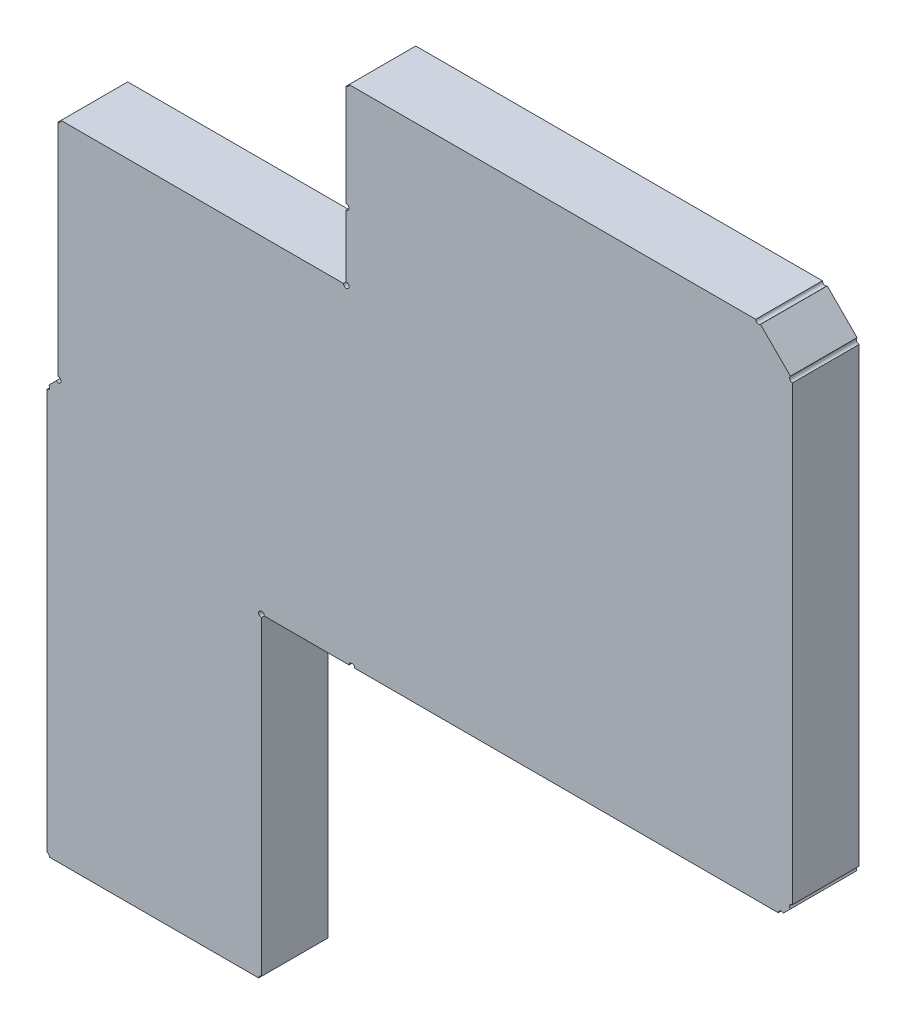
from build123d import *

# Parameters (mm, degrees)
EXTRUDE_1_DEPTH = 1.5


with BuildPart() as part:
    # 草图1 → 凸台-拉伸1 (new body)
    with BuildSketch(Plane.XY):
        with BuildLine():
            Line((91.141098719, 85.299098719), (90.976901281, 85.134901281))
            ThreePointArc((90.976901281, 85.134901281), (90.99066635, 85.114300398), (90.9955, 85.09))
            ThreePointArc((90.9955, 85.09), (90.976901281, 85.045098719), (90.932, 85.0265))
            Line((90.932, 85.0265), (90.932, 76.0095))
            ThreePointArc((90.932, 76.0095), (90.976901281, 75.990901281), (90.9955, 75.946))
            Line((90.9955, 75.946), (95.6945, 75.946))
            ThreePointArc((95.6945, 75.946), (95.713098719, 75.990901281), (95.758, 76.0095))
            Line((95.758, 76.0095), (95.758, 82.9945))
            ThreePointArc((95.758, 82.9945), (95.713098719, 83.102901281), (95.8215, 83.058))
            Line((95.8215, 83.058), (97.7265, 83.058))
            ThreePointArc((97.7265, 83.058), (97.79, 83.1215), (97.8535, 83.058))
            Line((97.8535, 83.058), (107.3785, 83.058))
            ThreePointArc((107.3785, 83.058), (107.417699602, 83.11666635), (107.486901281, 83.102901281))
            Line((107.486901281, 83.102901281), (107.651098719, 83.267098719))
            ThreePointArc((107.651098719, 83.267098719), (107.63733365, 83.336300398), (107.696, 83.3755))
            Line((107.696, 83.3755), (107.696, 93.5355))
            ThreePointArc((107.696, 93.5355), (107.63733365, 93.574699602), (107.651098719, 93.643901281))
            Line((107.651098719, 93.643901281), (106.978901281, 94.316098719))
            ThreePointArc((106.978901281, 94.316098719), (106.909699602, 94.30233365), (106.8705, 94.361))
            Line((106.8705, 94.361), (97.7265, 94.361))
            ThreePointArc((97.7265, 94.361), (97.707901281, 94.316098719), (97.663, 94.2975))
            Line((97.663, 94.2975), (97.663, 92.0115))
            ThreePointArc((97.663, 92.0115), (97.707901281, 91.992901281), (97.7265, 91.948))
            ThreePointArc((97.7265, 91.948), (97.707901281, 91.903098719), (97.663, 91.8845))
            Line((97.663, 91.8845), (97.663, 90.4875))
            ThreePointArc((97.663, 90.4875), (97.707901281, 90.468901281), (97.7265, 90.424))
            ThreePointArc((97.7265, 90.424), (97.663, 90.3605), (97.5995, 90.424))
            Line((97.5995, 90.424), (91.2495, 90.424))
            ThreePointArc((91.2495, 90.424), (91.230901281, 90.379098719), (91.186, 90.3605))
            Line((91.186, 90.3605), (91.186, 85.4075))
            ThreePointArc((91.186, 85.4075), (91.230901281, 85.388901281), (91.2495, 85.344))
            ThreePointArc((91.2495, 85.344), (91.210300398, 85.28533365), (91.141098719, 85.299098719))
        make_face()
    extrude(amount=EXTRUDE_1_DEPTH)


solid = part.part
